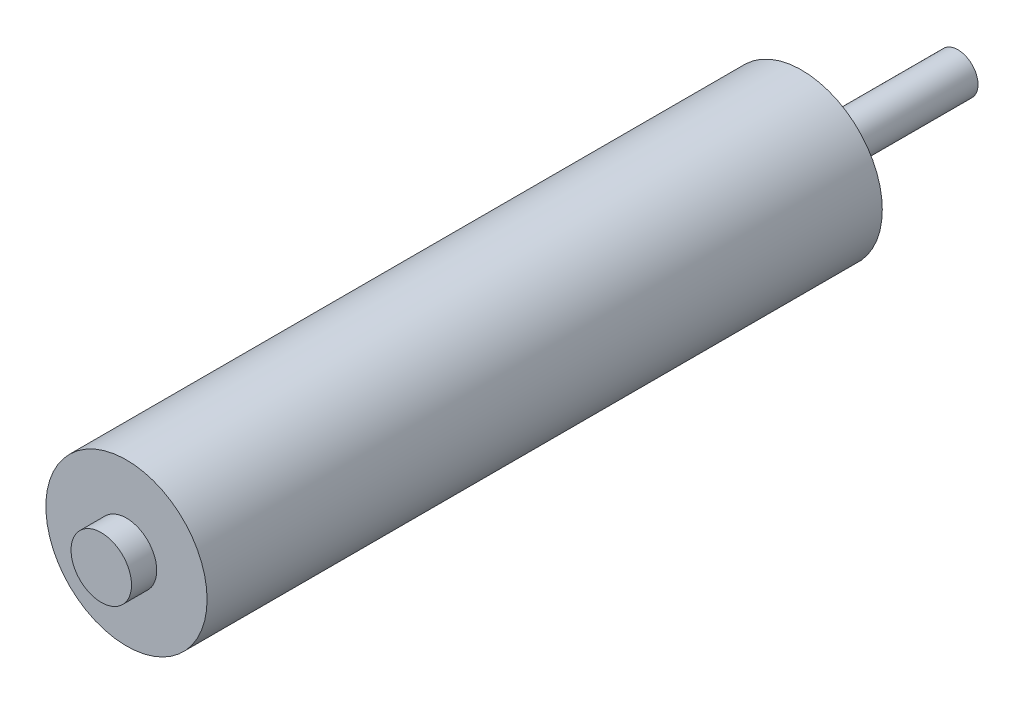
from build123d import *

# Parameters (mm, degrees)
SKETCH1_R           = 8
BOSS_EXTRUDE1_DEPTH = 67
SKETCH2_R           = 3
BOSS_EXTRUDE2_DEPTH = 2.5
SKETCH3_R           = 3
BOSS_EXTRUDE3_DEPTH = 2.5
SKETCH4_R           = 2
BOSS_EXTRUDE4_DEPTH = 13


with BuildPart() as part:
    # Sketch1 → Boss-Extrude1 (new body)
    with BuildSketch(Plane.XY):
        Circle(SKETCH1_R)
    extrude(amount=BOSS_EXTRUDE1_DEPTH)

    # Sketch2 → Boss-Extrude2 (add)
    with BuildSketch(Plane.XY.offset(67)):
        Circle(SKETCH2_R)
    extrude(amount=BOSS_EXTRUDE2_DEPTH)

    # Sketch3 → Boss-Extrude3 (add)
    with BuildSketch(Plane(origin=(0, 0, 0), x_dir=(-1, 0, 0), z_dir=(0, 0, -1))):
        Circle(SKETCH3_R)
    extrude(amount=BOSS_EXTRUDE3_DEPTH)

    # Sketch4 → Boss-Extrude4 (add)
    with BuildSketch(Plane(origin=(0, 0, -2.5), x_dir=(-1, 0, 0), z_dir=(0, 0, -1))):
        Circle(SKETCH4_R)
    extrude(amount=BOSS_EXTRUDE4_DEPTH)


solid = part.part
